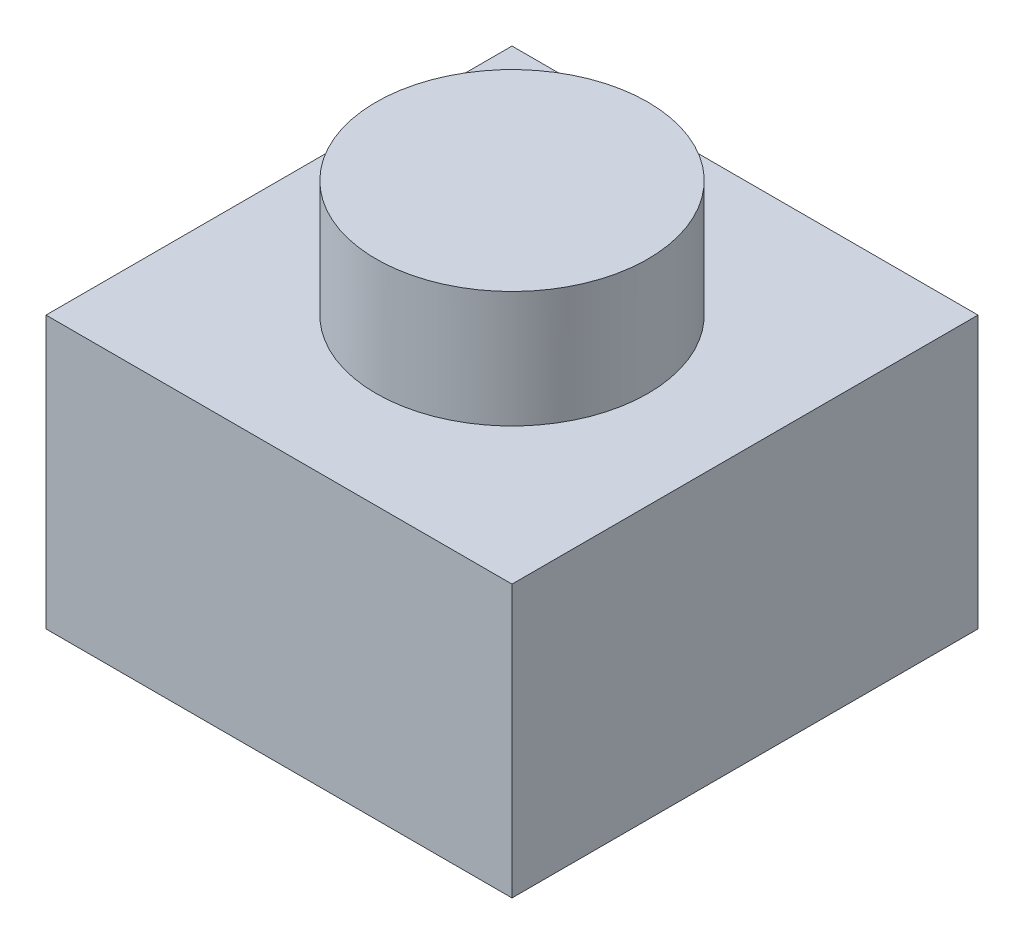
from build123d import *

# Parameters (mm, degrees)
SKETCH_1_W      = 6
SKETCH_1_H      = 6
EXTRUDE_1_DEPTH = 3.5
SKETCH_2_R      = 1.75
EXTRUDE_2_DEPTH = 5


with BuildPart() as part:
    # 草图1 → 凸台-拉伸1 (new body)
    with BuildSketch(Plane(origin=(0, 0, 0), x_dir=(1, 0, 0), z_dir=(0, 1, 0))):
        Rectangle(SKETCH_1_W, SKETCH_1_H)
    extrude(amount=EXTRUDE_1_DEPTH)

    # 草图2 → 凸台-拉伸2 (add)
    with BuildSketch(Plane.XZ):
        Circle(SKETCH_2_R)
    extrude(amount=-EXTRUDE_2_DEPTH)


solid = part.part
